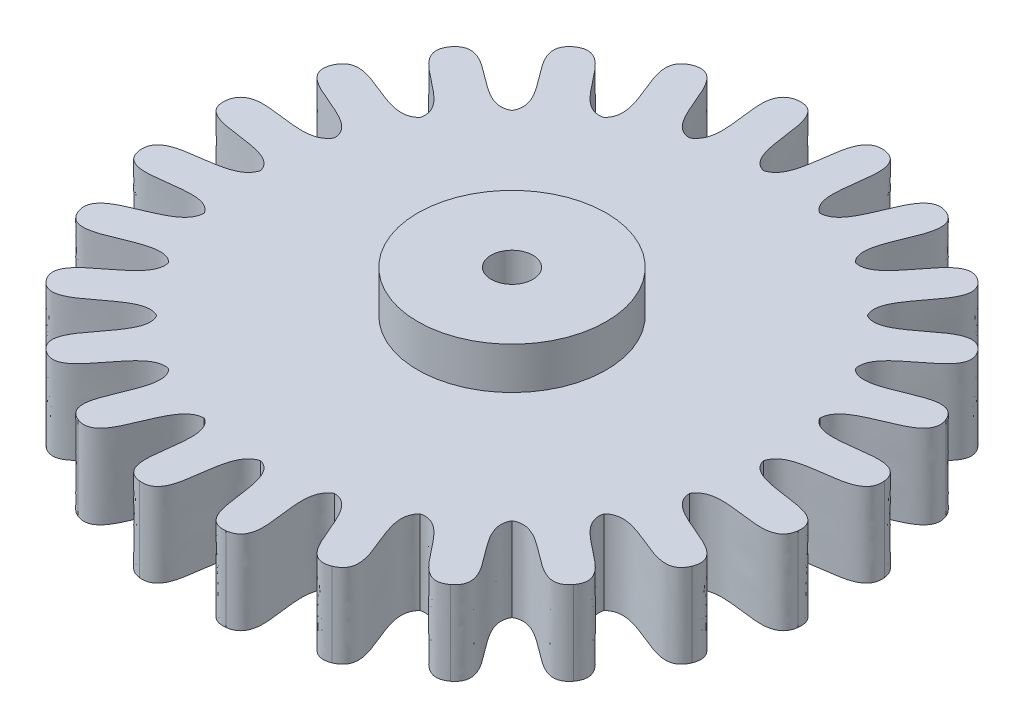
from build123d import *

# Parameters (mm, degrees)
SKETCH1_R           = 2.25
BOSS_EXTRUDE1_DEPTH = 1
BOSS_EXTRUDE3_DEPTH = 2
SKETCH7_R           = 0.5
CUT_EXTRUDE1_DEPTH  = 10


with BuildPart() as part:
    # Sketch1 → Boss-Extrude1 (new body)
    with BuildSketch(Plane(origin=(0, 0, 0), x_dir=(1, 0, 0), z_dir=(0, 1, 0))):
        Circle(SKETCH1_R)
    extrude(amount=BOSS_EXTRUDE1_DEPTH)

    # Sketch6 → Boss-Extrude3 (add)
    with BuildSketch(Plane.XZ):
        with BuildLine():
            add(Edge.make_bspline(
                [(0, 6), (-0.720447124, 6.19758351), (-0.179360812, 7.970134936), (-1.03527618, 7.863703305)],
                knots=[0, 0, 0, 0, 1, 1, 1, 1], degree=3))
            add(Edge.make_bspline(
                [(-1.552914271, 5.795554958), (-0.908154163, 6.17287141), (-1.889573473, 7.744981168), (-1.03527618, 7.863703305)],
                knots=[0, 0, 0, 0, 1, 1, 1, 1], degree=3))
            add(Edge.make_bspline(
                [(-1.552914271, 5.795554958), (-2.29995113, 5.799940536), (-2.236071955, 7.65213718), (-3.03527618, 7.32780492)],
                knots=[0, 0, 0, 0, 1, 1, 1, 1], degree=3))
            add(Edge.make_bspline(
                [(-3, 5.196152423), (-2.474866244, 5.727488324), (-3.829736448, 6.992019733), (-3.03527618, 7.32780492)],
                knots=[0, 0, 0, 0, 1, 1, 1, 1], degree=3))
            add(Edge.make_bspline(
                [(-3, 5.196152423), (-3.722717267, 5.0070412), (-4.140398488, 6.81265892), (-4.828427125, 6.29252874)],
                knots=[0, 0, 0, 0, 1, 1, 1, 1], degree=3))
            add(Edge.make_bspline(
                [(-4.242640687, 4.242640687), (-3.87292028, 4.891786374), (-5.508909214, 5.762563707), (-4.828427125, 6.29252874)],
                knots=[0, 0, 0, 0, 1, 1, 1, 1], degree=3))
            add(Edge.make_bspline(
                [(-4.242640687, 4.242640687), (-4.891786374, 3.87292028), (-5.762563707, 5.508909214), (-6.29252874, 4.828427125)],
                knots=[0, 0, 0, 0, 1, 1, 1, 1], degree=3))
            add(Edge.make_bspline(
                [(-5.196152423, 3), (-5.0070412, 3.722717267), (-6.81265892, 4.140398488), (-6.29252874, 4.828427125)],
                knots=[0, 0, 0, 0, 1, 1, 1, 1], degree=3))
            add(Edge.make_bspline(
                [(-5.196152423, 3), (-5.727488324, 2.474866244), (-6.992019733, 3.829736448), (-7.32780492, 3.03527618)],
                knots=[0, 0, 0, 0, 1, 1, 1, 1], degree=3))
            add(Edge.make_bspline(
                [(-5.795554958, 1.552914271), (-5.799940536, 2.29995113), (-7.65213718, 2.236071955), (-7.32780492, 3.03527618)],
                knots=[0, 0, 0, 0, 1, 1, 1, 1], degree=3))
            add(Edge.make_bspline(
                [(-5.795554958, 1.552914271), (-6.17287141, 0.908154163), (-7.744981168, 1.889573473), (-7.863703305, 1.03527618)],
                knots=[0, 0, 0, 0, 1, 1, 1, 1], degree=3))
            add(Edge.make_bspline(
                [(-6, 0), (-6.19758351, 0.720447124), (-7.970134936, 0.179360812), (-7.863703305, 1.03527618)],
                knots=[0, 0, 0, 0, 1, 1, 1, 1], degree=3))
            add(Edge.make_bspline(
                [(-6, 0), (-6.19758351, -0.720447124), (-7.970134936, -0.179360812), (-7.863703305, -1.03527618)],
                knots=[0, 0, 0, 0, 1, 1, 1, 1], degree=3))
            add(Edge.make_bspline(
                [(-5.795554958, -1.552914271), (-6.17287141, -0.908154163), (-7.744981168, -1.889573473), (-7.863703305, -1.03527618)],
                knots=[0, 0, 0, 0, 1, 1, 1, 1], degree=3))
            add(Edge.make_bspline(
                [(-5.795554958, -1.552914271), (-5.799940536, -2.29995113), (-7.65213718, -2.236071955), (-7.32780492, -3.03527618)],
                knots=[0, 0, 0, 0, 1, 1, 1, 1], degree=3))
            add(Edge.make_bspline(
                [(-5.196152423, -3), (-5.727488324, -2.474866244), (-6.992019733, -3.829736448), (-7.32780492, -3.03527618)],
                knots=[0, 0, 0, 0, 1, 1, 1, 1], degree=3))
            add(Edge.make_bspline(
                [(-5.196152423, -3), (-5.0070412, -3.722717267), (-6.81265892, -4.140398488), (-6.29252874, -4.828427125)],
                knots=[0, 0, 0, 0, 1, 1, 1, 1], degree=3))
            add(Edge.make_bspline(
                [(-4.242640687, -4.242640687), (-4.891786374, -3.87292028), (-5.762563707, -5.508909214), (-6.29252874, -4.828427125)],
                knots=[0, 0, 0, 0, 1, 1, 1, 1], degree=3))
            add(Edge.make_bspline(
                [(-4.242640687, -4.242640687), (-3.87292028, -4.891786374), (-5.508909214, -5.762563707), (-4.828427125, -6.29252874)],
                knots=[0, 0, 0, 0, 1, 1, 1, 1], degree=3))
            add(Edge.make_bspline(
                [(-3, -5.196152423), (-3.722717267, -5.0070412), (-4.140398488, -6.81265892), (-4.828427125, -6.29252874)],
                knots=[0, 0, 0, 0, 1, 1, 1, 1], degree=3))
            add(Edge.make_bspline(
                [(-3, -5.196152423), (-2.474866244, -5.727488324), (-3.829736448, -6.992019733), (-3.03527618, -7.32780492)],
                knots=[0, 0, 0, 0, 1, 1, 1, 1], degree=3))
            add(Edge.make_bspline(
                [(-1.552914271, -5.795554958), (-2.29995113, -5.799940536), (-2.236071955, -7.65213718), (-3.03527618, -7.32780492)],
                knots=[0, 0, 0, 0, 1, 1, 1, 1], degree=3))
            add(Edge.make_bspline(
                [(-1.552914271, -5.795554958), (-0.908154163, -6.17287141), (-1.889573473, -7.744981168), (-1.03527618, -7.863703305)],
                knots=[0, 0, 0, 0, 1, 1, 1, 1], degree=3))
            add(Edge.make_bspline(
                [(0, -6), (-0.720447124, -6.19758351), (-0.179360812, -7.970134936), (-1.03527618, -7.863703305)],
                knots=[0, 0, 0, 0, 1, 1, 1, 1], degree=3))
            add(Edge.make_bspline(
                [(0, -6), (0.720447124, -6.19758351), (0.179360812, -7.970134936), (1.03527618, -7.863703305)],
                knots=[0, 0, 0, 0, 1, 1, 1, 1], degree=3))
            add(Edge.make_bspline(
                [(1.552914271, -5.795554958), (0.908154163, -6.17287141), (1.889573473, -7.744981168), (1.03527618, -7.863703305)],
                knots=[0, 0, 0, 0, 1, 1, 1, 1], degree=3))
            add(Edge.make_bspline(
                [(1.552914271, -5.795554958), (2.29995113, -5.799940536), (2.236071955, -7.65213718), (3.03527618, -7.32780492)],
                knots=[0, 0, 0, 0, 1, 1, 1, 1], degree=3))
            add(Edge.make_bspline(
                [(3, -5.196152423), (2.474866244, -5.727488324), (3.829736448, -6.992019733), (3.03527618, -7.32780492)],
                knots=[0, 0, 0, 0, 1, 1, 1, 1], degree=3))
            add(Edge.make_bspline(
                [(3, -5.196152423), (3.722717267, -5.0070412), (4.140398488, -6.81265892), (4.828427125, -6.29252874)],
                knots=[0, 0, 0, 0, 1, 1, 1, 1], degree=3))
            add(Edge.make_bspline(
                [(4.242640687, -4.242640687), (3.87292028, -4.891786374), (5.508909214, -5.762563707), (4.828427125, -6.29252874)],
                knots=[0, 0, 0, 0, 1, 1, 1, 1], degree=3))
            add(Edge.make_bspline(
                [(4.242640687, -4.242640687), (4.891786374, -3.87292028), (5.762563707, -5.508909214), (6.29252874, -4.828427125)],
                knots=[0, 0, 0, 0, 1, 1, 1, 1], degree=3))
            add(Edge.make_bspline(
                [(5.196152423, -3), (5.0070412, -3.722717267), (6.81265892, -4.140398488), (6.29252874, -4.828427125)],
                knots=[0, 0, 0, 0, 1, 1, 1, 1], degree=3))
            add(Edge.make_bspline(
                [(5.196152423, -3), (5.727488324, -2.474866244), (6.992019733, -3.829736448), (7.32780492, -3.03527618)],
                knots=[0, 0, 0, 0, 1, 1, 1, 1], degree=3))
            add(Edge.make_bspline(
                [(5.795554958, -1.552914271), (5.799940536, -2.29995113), (7.65213718, -2.236071955), (7.32780492, -3.03527618)],
                knots=[0, 0, 0, 0, 1, 1, 1, 1], degree=3))
            add(Edge.make_bspline(
                [(5.795554958, -1.552914271), (6.17287141, -0.908154163), (7.744981168, -1.889573473), (7.863703305, -1.03527618)],
                knots=[0, 0, 0, 0, 1, 1, 1, 1], degree=3))
            add(Edge.make_bspline(
                [(6, 0), (6.19758351, -0.720447124), (7.970134936, -0.179360812), (7.863703305, -1.03527618)],
                knots=[0, 0, 0, 0, 1, 1, 1, 1], degree=3))
            add(Edge.make_bspline(
                [(6, 0), (6.19758351, 0.720447124), (7.970134936, 0.179360812), (7.863703305, 1.03527618)],
                knots=[0, 0, 0, 0, 1, 1, 1, 1], degree=3))
            add(Edge.make_bspline(
                [(5.795554958, 1.552914271), (6.17287141, 0.908154163), (7.744981168, 1.889573473), (7.863703305, 1.03527618)],
                knots=[0, 0, 0, 0, 1, 1, 1, 1], degree=3))
            add(Edge.make_bspline(
                [(5.795554958, 1.552914271), (5.799940536, 2.29995113), (7.65213718, 2.236071955), (7.32780492, 3.03527618)],
                knots=[0, 0, 0, 0, 1, 1, 1, 1], degree=3))
            add(Edge.make_bspline(
                [(5.196152423, 3), (5.727488324, 2.474866244), (6.992019733, 3.829736448), (7.32780492, 3.03527618)],
                knots=[0, 0, 0, 0, 1, 1, 1, 1], degree=3))
            add(Edge.make_bspline(
                [(5.196152423, 3), (5.0070412, 3.722717267), (6.81265892, 4.140398488), (6.29252874, 4.828427125)],
                knots=[0, 0, 0, 0, 1, 1, 1, 1], degree=3))
            add(Edge.make_bspline(
                [(4.242640687, 4.242640687), (4.891786374, 3.87292028), (5.762563707, 5.508909214), (6.29252874, 4.828427125)],
                knots=[0, 0, 0, 0, 1, 1, 1, 1], degree=3))
            add(Edge.make_bspline(
                [(4.242640687, 4.242640687), (3.87292028, 4.891786374), (5.508909214, 5.762563707), (4.828427125, 6.29252874)],
                knots=[0, 0, 0, 0, 1, 1, 1, 1], degree=3))
            add(Edge.make_bspline(
                [(3, 5.196152423), (3.722717267, 5.0070412), (4.140398488, 6.81265892), (4.828427125, 6.29252874)],
                knots=[0, 0, 0, 0, 1, 1, 1, 1], degree=3))
            add(Edge.make_bspline(
                [(3, 5.196152423), (2.474866244, 5.727488324), (3.829736448, 6.992019733), (3.03527618, 7.32780492)],
                knots=[0, 0, 0, 0, 1, 1, 1, 1], degree=3))
            add(Edge.make_bspline(
                [(1.552914271, 5.795554958), (2.29995113, 5.799940536), (2.236071955, 7.65213718), (3.03527618, 7.32780492)],
                knots=[0, 0, 0, 0, 1, 1, 1, 1], degree=3))
            add(Edge.make_bspline(
                [(1.552914271, 5.795554958), (0.908154163, 6.17287141), (1.889573473, 7.744981168), (1.03527618, 7.863703305)],
                knots=[0, 0, 0, 0, 1, 1, 1, 1], degree=3))
            add(Edge.make_bspline(
                [(0, 6), (0.720447124, 6.19758351), (0.179360812, 7.970134936), (1.03527618, 7.863703305)],
                knots=[0, 0, 0, 0, 1, 1, 1, 1], degree=3))
        make_face()
    extrude(amount=BOSS_EXTRUDE3_DEPTH)

    # Sketch7 → Cut-Extrude1 (cut)
    with BuildSketch(Plane(origin=(0, 1, 0), x_dir=(1, 0, 0), z_dir=(0, 1, 0))):
        Circle(SKETCH7_R)
    extrude(amount=-CUT_EXTRUDE1_DEPTH, mode=Mode.SUBTRACT)


solid = part.part
